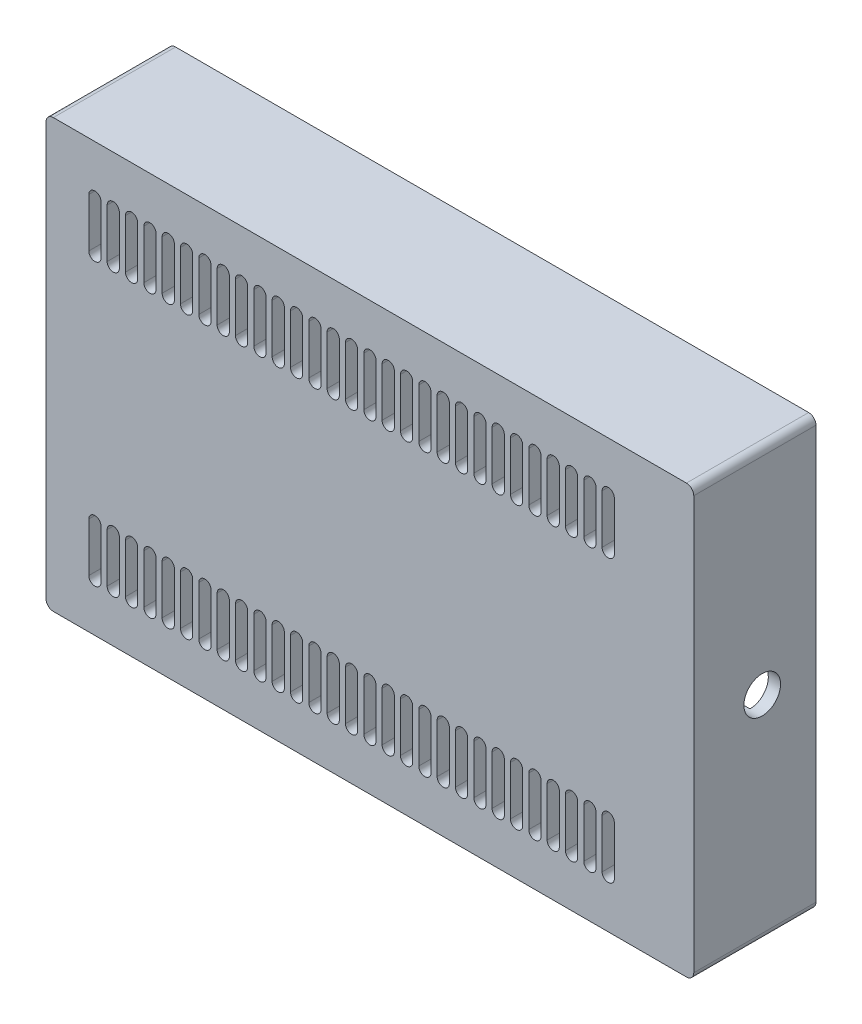
from build123d import *

# Parameters (mm, degrees)
SKETCH1_W             = 265
SKETCH1_H             = 175
BOSS_EXTRUDE1_DEPTH   = 50
SHELL1_T              = -5
FILLET1_R             = 3
SKETCH22_W            = 115
SKETCH22_H            = 70
CUT_EXTRUDE2_DEPTH    = 1.5
SKETCH15_R            = 4
BOSS_EXTRUDE5_DEPTH   = 13.95
FILLET3_R             = 5
SKETCH16_R            = 2.5
BOSS_EXTRUDE6_DEPTH   = 3
SKETCH23_W            = 15
SKETCH23_H            = 35
BOSS_EXTRUDE7_DEPTH   = 23
SKETCH27_R            = 1.65
CUT_EXTRUDE5_DEPTH    = 23
RIB1_REACH            = 174.187
SKETCH19_WALLS_W      = 2
SKETCH19_WALLS_H      = 353.383403917
RIB2_REACH            = 174.187
SKETCH20_WALLS_W      = 375.258359016
SKETCH20_WALLS_H      = 2
RIB12_REACH           = 174.187
SKETCH36_WALLS_W      = 360.258359016
SKETCH36_WALLS_H      = 2
SKETCH21_R            = 1.25
CUT_EXTRUDE1_DEPTH    = 13.95
SKETCH25_R            = 7.5
CUT_EXTRUDE3_DEPTH    = 21.1
FILLET4_R             = 3
CUT_EXTRUDE4_DEPTH    = 15
LPATTERN2_COUNT       = 29
LPATTERN2_PITCH       = 7.5
MIRROR3_COPY_1_DEPTH  = 15
MIRROR3_COPY_2_DEPTH  = 15
MIRROR3_COPY_3_DEPTH  = 15
MIRROR3_COPY_4_DEPTH  = 15
MIRROR3_COPY_5_DEPTH  = 15
MIRROR3_COPY_6_DEPTH  = 15
MIRROR3_COPY_7_DEPTH  = 15
MIRROR3_COPY_8_DEPTH  = 15
MIRROR3_COPY_9_DEPTH  = 15
MIRROR3_COPY_10_DEPTH = 15
MIRROR3_COPY_11_DEPTH = 15
MIRROR3_COPY_12_DEPTH = 15
MIRROR3_COPY_13_DEPTH = 15
MIRROR3_COPY_14_DEPTH = 15
MIRROR3_COPY_15_DEPTH = 15
MIRROR3_COPY_16_DEPTH = 15
MIRROR3_COPY_17_DEPTH = 15
MIRROR3_COPY_18_DEPTH = 15
MIRROR3_COPY_19_DEPTH = 15
MIRROR3_COPY_20_DEPTH = 15
MIRROR3_COPY_21_DEPTH = 15
MIRROR3_COPY_22_DEPTH = 15
MIRROR3_COPY_23_DEPTH = 15
MIRROR3_COPY_24_DEPTH = 15
MIRROR3_COPY_25_DEPTH = 15
MIRROR3_COPY_26_DEPTH = 15
MIRROR3_COPY_27_DEPTH = 15
MIRROR3_COPY_28_DEPTH = 15
SKETCH33_W            = 12
SKETCH33_H            = 13.5
CUT_EXTRUDE6_DEPTH    = 10.5


with BuildPart() as part:
    # Sketch1 → Boss-Extrude1 (new body)
    with BuildSketch(Plane.XY):
        with Locations((12.51, 0)):
            Rectangle(SKETCH1_W, SKETCH1_H)
    extrude(amount=BOSS_EXTRUDE1_DEPTH)

    # Shell1
    shell1_openings = [part.faces().sort_by_distance(p)[0] for p in [
        (12.51, 0, 0),
    ]]
    offset(amount=SHELL1_T, openings=shell1_openings, kind=Kind.INTERSECTION)

    # Fillet1
    fillet1_edges = [part.edges().sort_by_distance(p)[0] for p in [
        (-119.99, -87.5, 25),
        (145.01, -87.5, 25),
        (145.01, 87.5, 25),
        (-119.99, 87.5, 25),
    ]]
    fillet(fillet1_edges, radius=FILLET1_R)

    # Sketch22 → Cut-Extrude2 (cut)
    with BuildSketch(Plane(origin=(0, 0, 45), x_dir=(-1, 0, 0), z_dir=(0, 0, -1))):
        with Locations((47.5, 0)):
            Rectangle(SKETCH22_W, SKETCH22_H)
    extrude(amount=-CUT_EXTRUDE2_DEPTH, mode=Mode.SUBTRACT)

    # Sketch15 → Boss-Extrude5 (add)
    with BuildSketch(Plane(origin=(0, 0, 45), x_dir=(-1, 0, 0), z_dir=(0, 0, -1))):
        with Locations((-111.125, -3.89)):
            Circle(SKETCH15_R)
        with Locations((-111.125, 75.489955099)):
            Circle(SKETCH15_R)
        with Locations((111.125, -76.910044901)):
            Circle(SKETCH15_R)
        with Locations((-111.125, -76.910044901)):
            Circle(SKETCH15_R)
        with Locations((111.125, 75.489955099)):
            Circle(SKETCH15_R)
        with Locations((-57.15, 75.489955099)):
            Circle(SKETCH15_R)
        with Locations((0, 75.489955099)):
            Circle(SKETCH15_R)
        with Locations((57.145, 75.489955099)):
            Circle(SKETCH15_R)
        with Locations((-57.15, -76.910044901)):
            Circle(SKETCH15_R)
        with Locations((0, -76.910044901)):
            Circle(SKETCH15_R)
        with Locations((57.145, -76.910044901)):
            Circle(SKETCH15_R)
    extrude(amount=BOSS_EXTRUDE5_DEPTH)

    # Fillet3
    fillet3_edges = [part.edges().sort_by_distance(p)[0] for p in [
        (10, -35, 45.75),
        (10, 35, 45.75),
        (-105, 35, 45.75),
        (-105, -35, 45.75),
    ]]
    fillet(fillet3_edges, radius=FILLET3_R)

    # Sketch16 → Boss-Extrude6 (add)
    with BuildSketch(Plane(origin=(0, 0, 46.5), x_dir=(-1, 0, 0), z_dir=(0, 0, -1))):
        with Locations((85.245, -24.970044901)):
            Circle(SKETCH16_R)
        with Locations((10.115, -24.970042101)):
            Circle(SKETCH16_R)
        with Locations((34.445, -9.770044901)):
            Circle(SKETCH16_R)
        with Locations((3.035, 23.229955099)):
            Circle(SKETCH16_R)
        with Locations((34.445, 18.129955099)):
            Circle(SKETCH16_R)
        with Locations((85.665, 23.229955099)):
            Circle(SKETCH16_R)
    extrude(amount=BOSS_EXTRUDE6_DEPTH)

    # Sketch23 → Boss-Extrude7 (add)
    with BuildSketch(Plane(origin=(0, 0, 45), x_dir=(-1, 0, 0), z_dir=(0, 0, -1))):
        with Locations((-132.51, 0)):
            Rectangle(SKETCH23_W, SKETCH23_H)
    extrude(amount=BOSS_EXTRUDE7_DEPTH)

    # Sketch27 → Cut-Extrude5 (cut)
    with BuildSketch(Plane(origin=(0, 0, 22), x_dir=(-1, 0, 0), z_dir=(0, 0, -1))):
        with Locations((-132.51, -12)):
            Circle(SKETCH27_R)
        with Locations((-132.51, 12)):
            Circle(SKETCH27_R)
    extrude(amount=-CUT_EXTRUDE5_DEPTH, mode=Mode.SUBTRACT)

    # Sketch19 walls → Rib1 (add, up to next)
    with BuildSketch(Plane(origin=(0, 0, 31.05), x_dir=(-1, 0, 0), z_dir=(0, 0, -1)), mode=Mode.PRIVATE) as rib1_sk1:
        with Locations((-57.15, 78.99497755)):
            Rectangle(SKETCH19_WALLS_W, SKETCH19_WALLS_H)
    rib1_tool1 = extrude(rib1_sk1.sketch, amount=-RIB1_REACH, mode=Mode.PRIVATE) - part.part
    # Sketch19 walls → Rib1 (add, up to next)
    with BuildSketch(Plane(origin=(0, 0, 31.05), x_dir=(-1, 0, 0), z_dir=(0, 0, -1)), mode=Mode.PRIVATE) as rib1_sk2:
        with Locations((-111.125, 78.99497755)):
            Rectangle(SKETCH19_WALLS_W, SKETCH19_WALLS_H)
    rib1_tool2 = extrude(rib1_sk2.sketch, amount=-RIB1_REACH, mode=Mode.PRIVATE) - part.part
    # Sketch19 walls → Rib1 (add, up to next)
    with BuildSketch(Plane(origin=(0, 0, 31.05), x_dir=(-1, 0, 0), z_dir=(0, 0, -1)), mode=Mode.PRIVATE) as rib1_sk3:
        with Locations((0, 78.99497755)):
            Rectangle(SKETCH19_WALLS_W, SKETCH19_WALLS_H)
    rib1_tool3 = extrude(rib1_sk3.sketch, amount=-RIB1_REACH, mode=Mode.PRIVATE) - part.part
    # Sketch19 walls → Rib1 (add, up to next)
    with BuildSketch(Plane(origin=(0, 0, 31.05), x_dir=(-1, 0, 0), z_dir=(0, 0, -1)), mode=Mode.PRIVATE) as rib1_sk4:
        with Locations((57.145, 78.99497755)):
            Rectangle(SKETCH19_WALLS_W, SKETCH19_WALLS_H)
    rib1_tool4 = extrude(rib1_sk4.sketch, amount=-RIB1_REACH, mode=Mode.PRIVATE) - part.part
    # Sketch19 walls → Rib1 (add, up to next)
    with BuildSketch(Plane(origin=(0, 0, 31.05), x_dir=(-1, 0, 0), z_dir=(0, 0, -1)), mode=Mode.PRIVATE) as rib1_sk5:
        with Locations((111.125, 78.99497755)):
            Rectangle(SKETCH19_WALLS_W, SKETCH19_WALLS_H)
    rib1_tool5 = extrude(rib1_sk5.sketch, amount=-RIB1_REACH, mode=Mode.PRIVATE) - part.part
    rib1_1 = rib1_tool1.solids().sort_by_distance((57.15, 78.99497755, 31.05))[0]
    add(rib1_1)
    rib1_2 = rib1_tool2.solids().sort_by_distance((111.125, 78.99497755, 31.05))[0]
    add(rib1_2)
    rib1_3 = rib1_tool3.solids().sort_by_distance((0, 78.99497755, 31.05))[0]
    add(rib1_3)
    rib1_4 = rib1_tool4.solids().sort_by_distance((-57.145, 78.99497755, 31.05))[0]
    add(rib1_4)
    rib1_5 = rib1_tool5.solids().sort_by_distance((-111.125, 78.99497755, 31.05))[0]
    add(rib1_5)
    rib1 = rib1_1 + rib1_2 + rib1_3 + rib1_4 + rib1_5  # Rib1 as one shape, for the pattern or mirror that repeats it

    # Sketch20 walls → Rib2 (add, up to next)
    with BuildSketch(Plane(origin=(0, 0, 31.05), x_dir=(-1, 0, 0), z_dir=(0, 0, -1)), mode=Mode.PRIVATE) as rib2_sk1:
        with Locations((-125.5675, 75.489955099)):
            Rectangle(SKETCH20_WALLS_W, SKETCH20_WALLS_H)
    rib2_tool1 = extrude(rib2_sk1.sketch, amount=-RIB2_REACH, mode=Mode.PRIVATE) - part.part
    # Sketch20 walls → Rib2 (add, up to next)
    with BuildSketch(Plane(origin=(0, 0, 31.05), x_dir=(-1, 0, 0), z_dir=(0, 0, -1)), mode=Mode.PRIVATE) as rib2_sk2:
        with Locations((-125.5675, -76.910044901)):
            Rectangle(SKETCH20_WALLS_W, SKETCH20_WALLS_H)
    rib2_tool2 = extrude(rib2_sk2.sketch, amount=-RIB2_REACH, mode=Mode.PRIVATE) - part.part
    add(rib2_tool1.solids().sort_by_distance((125.5675, 75.489955099, 31.05))[0])
    add(rib2_tool2.solids().sort_by_distance((125.5675, -76.910044901, 31.05))[0])

    # Sketch36 walls → Rib12 (add, up to next)
    with BuildSketch(Plane(origin=(0, 0, 31.05), x_dir=(-1, 0, 0), z_dir=(0, 0, -1)), mode=Mode.PRIVATE) as rib12_sk1:
        with Locations((-118.0675, -3.89)):
            Rectangle(SKETCH36_WALLS_W, SKETCH36_WALLS_H)
    rib12_tool1 = extrude(rib12_sk1.sketch, amount=-RIB12_REACH, mode=Mode.PRIVATE) - part.part
    add(rib12_tool1.solids().sort_by_distance((118.0675, -3.89, 31.05))[0])

    # Mirror2: Rib1 across plane
    add(rib1.mirror(Plane.ZX))

    # Sketch21 → Cut-Extrude1 (cut)
    with BuildSketch(Plane(origin=(0, 0, 31.05), x_dir=(-1, 0, 0), z_dir=(0, 0, -1))):
        with Locations((-111.125, 75.489955099)):
            Circle(SKETCH21_R)
        with Locations((-57.15, 75.489955099)):
            Circle(SKETCH21_R)
        with Locations((0, 75.489955099)):
            Circle(SKETCH21_R)
        with Locations((57.145, 75.489955099)):
            Circle(SKETCH21_R)
        with Locations((111.125, 75.489955099)):
            Circle(SKETCH21_R)
        with Locations((111.125, -76.910044901)):
            Circle(SKETCH21_R)
        with Locations((57.145, -76.910044901)):
            Circle(SKETCH21_R)
        with Locations((0, -76.910044901)):
            Circle(SKETCH21_R)
        with Locations((-57.15, -76.910044901)):
            Circle(SKETCH21_R)
        with Locations((-111.125, -76.910044901)):
            Circle(SKETCH21_R)
        with Locations((-111.125, -3.89)):
            Circle(SKETCH21_R)
    extrude(amount=-CUT_EXTRUDE1_DEPTH, mode=Mode.SUBTRACT)

    # Sketch25 → Cut-Extrude3 (cut)
    with BuildSketch(Plane.ZY.offset(-125.01)):
        with Locations((22, 0)):
            Circle(SKETCH25_R)
    extrude(amount=-CUT_EXTRUDE3_DEPTH, mode=Mode.SUBTRACT)

    # Fillet4
    fillet4_edges = [part.edges().sort_by_distance(p)[0] for p in [
        (125.01, -17.5, 33.5),
        (125.01, 17.5, 33.5),
    ]]
    fillet(fillet4_edges, radius=FILLET4_R)

    # Sketch28 → Cut-Extrude4 (cut)
    with BuildSketch(Plane.XY.offset(50)):
        with BuildLine():
            Line((-102.49, 47.5), (-102.49, 67.5))
            ThreePointArc((-102.49, 67.5), (-99.99, 70), (-97.49, 67.5))
            Line((-97.49, 67.5), (-97.49, 47.5))
            ThreePointArc((-97.49, 47.5), (-99.99, 45), (-102.49, 47.5))
        make_face()
    cut_extrude4 = extrude(amount=-CUT_EXTRUDE4_DEPTH, mode=Mode.SUBTRACT)

    # LPattern2: Cut-Extrude4 ×29
    with Locations(*[(i * LPATTERN2_PITCH, 0, 0) for i in range(1, LPATTERN2_COUNT)]):
        add(cut_extrude4, mode=Mode.SUBTRACT)

    # Mirror3: Cut-Extrude4 across plane
    add(cut_extrude4.mirror(Plane.ZX), mode=Mode.SUBTRACT)

    # Mirror3 copy 1 sketch → Mirror3 copy 1 (cut)
    with BuildSketch(Plane(origin=(7.5, 0, 50), x_dir=(1, 0, 0), z_dir=(0, 0, 1))):
        with BuildLine():
            Line((-102.49, -47.5), (-102.49, -67.5))
            ThreePointArc((-102.49, -67.5), (-99.99, -70), (-97.49, -67.5))
            Line((-97.49, -67.5), (-97.49, -47.5))
            ThreePointArc((-97.49, -47.5), (-99.99, -45), (-102.49, -47.5))
        make_face()
    extrude(amount=-MIRROR3_COPY_1_DEPTH, mode=Mode.SUBTRACT)

    # Mirror3 copy 2 sketch → Mirror3 copy 2 (cut)
    with BuildSketch(Plane(origin=(15, 0, 50), x_dir=(1, 0, 0), z_dir=(0, 0, 1))):
        with BuildLine():
            Line((-102.49, -47.5), (-102.49, -67.5))
            ThreePointArc((-102.49, -67.5), (-99.99, -70), (-97.49, -67.5))
            Line((-97.49, -67.5), (-97.49, -47.5))
            ThreePointArc((-97.49, -47.5), (-99.99, -45), (-102.49, -47.5))
        make_face()
    extrude(amount=-MIRROR3_COPY_2_DEPTH, mode=Mode.SUBTRACT)

    # Mirror3 copy 3 sketch → Mirror3 copy 3 (cut)
    with BuildSketch(Plane(origin=(22.5, 0, 50), x_dir=(1, 0, 0), z_dir=(0, 0, 1))):
        with BuildLine():
            Line((-102.49, -47.5), (-102.49, -67.5))
            ThreePointArc((-102.49, -67.5), (-99.99, -70), (-97.49, -67.5))
            Line((-97.49, -67.5), (-97.49, -47.5))
            ThreePointArc((-97.49, -47.5), (-99.99, -45), (-102.49, -47.5))
        make_face()
    extrude(amount=-MIRROR3_COPY_3_DEPTH, mode=Mode.SUBTRACT)

    # Mirror3 copy 4 sketch → Mirror3 copy 4 (cut)
    with BuildSketch(Plane(origin=(30, 0, 50), x_dir=(1, 0, 0), z_dir=(0, 0, 1))):
        with BuildLine():
            Line((-102.49, -47.5), (-102.49, -67.5))
            ThreePointArc((-102.49, -67.5), (-99.99, -70), (-97.49, -67.5))
            Line((-97.49, -67.5), (-97.49, -47.5))
            ThreePointArc((-97.49, -47.5), (-99.99, -45), (-102.49, -47.5))
        make_face()
    extrude(amount=-MIRROR3_COPY_4_DEPTH, mode=Mode.SUBTRACT)

    # Mirror3 copy 5 sketch → Mirror3 copy 5 (cut)
    with BuildSketch(Plane(origin=(37.5, 0, 50), x_dir=(1, 0, 0), z_dir=(0, 0, 1))):
        with BuildLine():
            Line((-102.49, -47.5), (-102.49, -67.5))
            ThreePointArc((-102.49, -67.5), (-99.99, -70), (-97.49, -67.5))
            Line((-97.49, -67.5), (-97.49, -47.5))
            ThreePointArc((-97.49, -47.5), (-99.99, -45), (-102.49, -47.5))
        make_face()
    extrude(amount=-MIRROR3_COPY_5_DEPTH, mode=Mode.SUBTRACT)

    # Mirror3 copy 6 sketch → Mirror3 copy 6 (cut)
    with BuildSketch(Plane(origin=(45, 0, 50), x_dir=(1, 0, 0), z_dir=(0, 0, 1))):
        with BuildLine():
            Line((-102.49, -47.5), (-102.49, -67.5))
            ThreePointArc((-102.49, -67.5), (-99.99, -70), (-97.49, -67.5))
            Line((-97.49, -67.5), (-97.49, -47.5))
            ThreePointArc((-97.49, -47.5), (-99.99, -45), (-102.49, -47.5))
        make_face()
    extrude(amount=-MIRROR3_COPY_6_DEPTH, mode=Mode.SUBTRACT)

    # Mirror3 copy 7 sketch → Mirror3 copy 7 (cut)
    with BuildSketch(Plane(origin=(52.5, 0, 50), x_dir=(1, 0, 0), z_dir=(0, 0, 1))):
        with BuildLine():
            Line((-102.49, -47.5), (-102.49, -67.5))
            ThreePointArc((-102.49, -67.5), (-99.99, -70), (-97.49, -67.5))
            Line((-97.49, -67.5), (-97.49, -47.5))
            ThreePointArc((-97.49, -47.5), (-99.99, -45), (-102.49, -47.5))
        make_face()
    extrude(amount=-MIRROR3_COPY_7_DEPTH, mode=Mode.SUBTRACT)

    # Mirror3 copy 8 sketch → Mirror3 copy 8 (cut)
    with BuildSketch(Plane(origin=(60, 0, 50), x_dir=(1, 0, 0), z_dir=(0, 0, 1))):
        with BuildLine():
            Line((-102.49, -47.5), (-102.49, -67.5))
            ThreePointArc((-102.49, -67.5), (-99.99, -70), (-97.49, -67.5))
            Line((-97.49, -67.5), (-97.49, -47.5))
            ThreePointArc((-97.49, -47.5), (-99.99, -45), (-102.49, -47.5))
        make_face()
    extrude(amount=-MIRROR3_COPY_8_DEPTH, mode=Mode.SUBTRACT)

    # Mirror3 copy 9 sketch → Mirror3 copy 9 (cut)
    with BuildSketch(Plane(origin=(67.5, 0, 50), x_dir=(1, 0, 0), z_dir=(0, 0, 1))):
        with BuildLine():
            Line((-102.49, -47.5), (-102.49, -67.5))
            ThreePointArc((-102.49, -67.5), (-99.99, -70), (-97.49, -67.5))
            Line((-97.49, -67.5), (-97.49, -47.5))
            ThreePointArc((-97.49, -47.5), (-99.99, -45), (-102.49, -47.5))
        make_face()
    extrude(amount=-MIRROR3_COPY_9_DEPTH, mode=Mode.SUBTRACT)

    # Mirror3 copy 10 sketch → Mirror3 copy 10 (cut)
    with BuildSketch(Plane(origin=(75, 0, 50), x_dir=(1, 0, 0), z_dir=(0, 0, 1))):
        with BuildLine():
            Line((-102.49, -47.5), (-102.49, -67.5))
            ThreePointArc((-102.49, -67.5), (-99.99, -70), (-97.49, -67.5))
            Line((-97.49, -67.5), (-97.49, -47.5))
            ThreePointArc((-97.49, -47.5), (-99.99, -45), (-102.49, -47.5))
        make_face()
    extrude(amount=-MIRROR3_COPY_10_DEPTH, mode=Mode.SUBTRACT)

    # Mirror3 copy 11 sketch → Mirror3 copy 11 (cut)
    with BuildSketch(Plane(origin=(82.5, 0, 50), x_dir=(1, 0, 0), z_dir=(0, 0, 1))):
        with BuildLine():
            Line((-102.49, -47.5), (-102.49, -67.5))
            ThreePointArc((-102.49, -67.5), (-99.99, -70), (-97.49, -67.5))
            Line((-97.49, -67.5), (-97.49, -47.5))
            ThreePointArc((-97.49, -47.5), (-99.99, -45), (-102.49, -47.5))
        make_face()
    extrude(amount=-MIRROR3_COPY_11_DEPTH, mode=Mode.SUBTRACT)

    # Mirror3 copy 12 sketch → Mirror3 copy 12 (cut)
    with BuildSketch(Plane(origin=(90, 0, 50), x_dir=(1, 0, 0), z_dir=(0, 0, 1))):
        with BuildLine():
            Line((-102.49, -47.5), (-102.49, -67.5))
            ThreePointArc((-102.49, -67.5), (-99.99, -70), (-97.49, -67.5))
            Line((-97.49, -67.5), (-97.49, -47.5))
            ThreePointArc((-97.49, -47.5), (-99.99, -45), (-102.49, -47.5))
        make_face()
    extrude(amount=-MIRROR3_COPY_12_DEPTH, mode=Mode.SUBTRACT)

    # Mirror3 copy 13 sketch → Mirror3 copy 13 (cut)
    with BuildSketch(Plane(origin=(97.5, 0, 50), x_dir=(1, 0, 0), z_dir=(0, 0, 1))):
        with BuildLine():
            Line((-102.49, -47.5), (-102.49, -67.5))
            ThreePointArc((-102.49, -67.5), (-99.99, -70), (-97.49, -67.5))
            Line((-97.49, -67.5), (-97.49, -47.5))
            ThreePointArc((-97.49, -47.5), (-99.99, -45), (-102.49, -47.5))
        make_face()
    extrude(amount=-MIRROR3_COPY_13_DEPTH, mode=Mode.SUBTRACT)

    # Mirror3 copy 14 sketch → Mirror3 copy 14 (cut)
    with BuildSketch(Plane(origin=(105, 0, 50), x_dir=(1, 0, 0), z_dir=(0, 0, 1))):
        with BuildLine():
            Line((-102.49, -47.5), (-102.49, -67.5))
            ThreePointArc((-102.49, -67.5), (-99.99, -70), (-97.49, -67.5))
            Line((-97.49, -67.5), (-97.49, -47.5))
            ThreePointArc((-97.49, -47.5), (-99.99, -45), (-102.49, -47.5))
        make_face()
    extrude(amount=-MIRROR3_COPY_14_DEPTH, mode=Mode.SUBTRACT)

    # Mirror3 copy 15 sketch → Mirror3 copy 15 (cut)
    with BuildSketch(Plane(origin=(112.5, 0, 50), x_dir=(1, 0, 0), z_dir=(0, 0, 1))):
        with BuildLine():
            Line((-102.49, -47.5), (-102.49, -67.5))
            ThreePointArc((-102.49, -67.5), (-99.99, -70), (-97.49, -67.5))
            Line((-97.49, -67.5), (-97.49, -47.5))
            ThreePointArc((-97.49, -47.5), (-99.99, -45), (-102.49, -47.5))
        make_face()
    extrude(amount=-MIRROR3_COPY_15_DEPTH, mode=Mode.SUBTRACT)

    # Mirror3 copy 16 sketch → Mirror3 copy 16 (cut)
    with BuildSketch(Plane(origin=(120, 0, 50), x_dir=(1, 0, 0), z_dir=(0, 0, 1))):
        with BuildLine():
            Line((-102.49, -47.5), (-102.49, -67.5))
            ThreePointArc((-102.49, -67.5), (-99.99, -70), (-97.49, -67.5))
            Line((-97.49, -67.5), (-97.49, -47.5))
            ThreePointArc((-97.49, -47.5), (-99.99, -45), (-102.49, -47.5))
        make_face()
    extrude(amount=-MIRROR3_COPY_16_DEPTH, mode=Mode.SUBTRACT)

    # Mirror3 copy 17 sketch → Mirror3 copy 17 (cut)
    with BuildSketch(Plane(origin=(127.5, 0, 50), x_dir=(1, 0, 0), z_dir=(0, 0, 1))):
        with BuildLine():
            Line((-102.49, -47.5), (-102.49, -67.5))
            ThreePointArc((-102.49, -67.5), (-99.99, -70), (-97.49, -67.5))
            Line((-97.49, -67.5), (-97.49, -47.5))
            ThreePointArc((-97.49, -47.5), (-99.99, -45), (-102.49, -47.5))
        make_face()
    extrude(amount=-MIRROR3_COPY_17_DEPTH, mode=Mode.SUBTRACT)

    # Mirror3 copy 18 sketch → Mirror3 copy 18 (cut)
    with BuildSketch(Plane(origin=(135, 0, 50), x_dir=(1, 0, 0), z_dir=(0, 0, 1))):
        with BuildLine():
            Line((-102.49, -47.5), (-102.49, -67.5))
            ThreePointArc((-102.49, -67.5), (-99.99, -70), (-97.49, -67.5))
            Line((-97.49, -67.5), (-97.49, -47.5))
            ThreePointArc((-97.49, -47.5), (-99.99, -45), (-102.49, -47.5))
        make_face()
    extrude(amount=-MIRROR3_COPY_18_DEPTH, mode=Mode.SUBTRACT)

    # Mirror3 copy 19 sketch → Mirror3 copy 19 (cut)
    with BuildSketch(Plane(origin=(142.5, 0, 50), x_dir=(1, 0, 0), z_dir=(0, 0, 1))):
        with BuildLine():
            Line((-102.49, -47.5), (-102.49, -67.5))
            ThreePointArc((-102.49, -67.5), (-99.99, -70), (-97.49, -67.5))
            Line((-97.49, -67.5), (-97.49, -47.5))
            ThreePointArc((-97.49, -47.5), (-99.99, -45), (-102.49, -47.5))
        make_face()
    extrude(amount=-MIRROR3_COPY_19_DEPTH, mode=Mode.SUBTRACT)

    # Mirror3 copy 20 sketch → Mirror3 copy 20 (cut)
    with BuildSketch(Plane(origin=(150, 0, 50), x_dir=(1, 0, 0), z_dir=(0, 0, 1))):
        with BuildLine():
            Line((-102.49, -47.5), (-102.49, -67.5))
            ThreePointArc((-102.49, -67.5), (-99.99, -70), (-97.49, -67.5))
            Line((-97.49, -67.5), (-97.49, -47.5))
            ThreePointArc((-97.49, -47.5), (-99.99, -45), (-102.49, -47.5))
        make_face()
    extrude(amount=-MIRROR3_COPY_20_DEPTH, mode=Mode.SUBTRACT)

    # Mirror3 copy 21 sketch → Mirror3 copy 21 (cut)
    with BuildSketch(Plane(origin=(157.5, 0, 50), x_dir=(1, 0, 0), z_dir=(0, 0, 1))):
        with BuildLine():
            Line((-102.49, -47.5), (-102.49, -67.5))
            ThreePointArc((-102.49, -67.5), (-99.99, -70), (-97.49, -67.5))
            Line((-97.49, -67.5), (-97.49, -47.5))
            ThreePointArc((-97.49, -47.5), (-99.99, -45), (-102.49, -47.5))
        make_face()
    extrude(amount=-MIRROR3_COPY_21_DEPTH, mode=Mode.SUBTRACT)

    # Mirror3 copy 22 sketch → Mirror3 copy 22 (cut)
    with BuildSketch(Plane(origin=(165, 0, 50), x_dir=(1, 0, 0), z_dir=(0, 0, 1))):
        with BuildLine():
            Line((-102.49, -47.5), (-102.49, -67.5))
            ThreePointArc((-102.49, -67.5), (-99.99, -70), (-97.49, -67.5))
            Line((-97.49, -67.5), (-97.49, -47.5))
            ThreePointArc((-97.49, -47.5), (-99.99, -45), (-102.49, -47.5))
        make_face()
    extrude(amount=-MIRROR3_COPY_22_DEPTH, mode=Mode.SUBTRACT)

    # Mirror3 copy 23 sketch → Mirror3 copy 23 (cut)
    with BuildSketch(Plane(origin=(172.5, 0, 50), x_dir=(1, 0, 0), z_dir=(0, 0, 1))):
        with BuildLine():
            Line((-102.49, -47.5), (-102.49, -67.5))
            ThreePointArc((-102.49, -67.5), (-99.99, -70), (-97.49, -67.5))
            Line((-97.49, -67.5), (-97.49, -47.5))
            ThreePointArc((-97.49, -47.5), (-99.99, -45), (-102.49, -47.5))
        make_face()
    extrude(amount=-MIRROR3_COPY_23_DEPTH, mode=Mode.SUBTRACT)

    # Mirror3 copy 24 sketch → Mirror3 copy 24 (cut)
    with BuildSketch(Plane(origin=(180, 0, 50), x_dir=(1, 0, 0), z_dir=(0, 0, 1))):
        with BuildLine():
            Line((-102.49, -47.5), (-102.49, -67.5))
            ThreePointArc((-102.49, -67.5), (-99.99, -70), (-97.49, -67.5))
            Line((-97.49, -67.5), (-97.49, -47.5))
            ThreePointArc((-97.49, -47.5), (-99.99, -45), (-102.49, -47.5))
        make_face()
    extrude(amount=-MIRROR3_COPY_24_DEPTH, mode=Mode.SUBTRACT)

    # Mirror3 copy 25 sketch → Mirror3 copy 25 (cut)
    with BuildSketch(Plane(origin=(187.5, 0, 50), x_dir=(1, 0, 0), z_dir=(0, 0, 1))):
        with BuildLine():
            Line((-102.49, -47.5), (-102.49, -67.5))
            ThreePointArc((-102.49, -67.5), (-99.99, -70), (-97.49, -67.5))
            Line((-97.49, -67.5), (-97.49, -47.5))
            ThreePointArc((-97.49, -47.5), (-99.99, -45), (-102.49, -47.5))
        make_face()
    extrude(amount=-MIRROR3_COPY_25_DEPTH, mode=Mode.SUBTRACT)

    # Mirror3 copy 26 sketch → Mirror3 copy 26 (cut)
    with BuildSketch(Plane(origin=(195, 0, 50), x_dir=(1, 0, 0), z_dir=(0, 0, 1))):
        with BuildLine():
            Line((-102.49, -47.5), (-102.49, -67.5))
            ThreePointArc((-102.49, -67.5), (-99.99, -70), (-97.49, -67.5))
            Line((-97.49, -67.5), (-97.49, -47.5))
            ThreePointArc((-97.49, -47.5), (-99.99, -45), (-102.49, -47.5))
        make_face()
    extrude(amount=-MIRROR3_COPY_26_DEPTH, mode=Mode.SUBTRACT)

    # Mirror3 copy 27 sketch → Mirror3 copy 27 (cut)
    with BuildSketch(Plane(origin=(202.5, 0, 50), x_dir=(1, 0, 0), z_dir=(0, 0, 1))):
        with BuildLine():
            Line((-102.49, -47.5), (-102.49, -67.5))
            ThreePointArc((-102.49, -67.5), (-99.99, -70), (-97.49, -67.5))
            Line((-97.49, -67.5), (-97.49, -47.5))
            ThreePointArc((-97.49, -47.5), (-99.99, -45), (-102.49, -47.5))
        make_face()
    extrude(amount=-MIRROR3_COPY_27_DEPTH, mode=Mode.SUBTRACT)

    # Mirror3 copy 28 sketch → Mirror3 copy 28 (cut)
    with BuildSketch(Plane(origin=(210, 0, 50), x_dir=(1, 0, 0), z_dir=(0, 0, 1))):
        with BuildLine():
            Line((-102.49, -47.5), (-102.49, -67.5))
            ThreePointArc((-102.49, -67.5), (-99.99, -70), (-97.49, -67.5))
            Line((-97.49, -67.5), (-97.49, -47.5))
            ThreePointArc((-97.49, -47.5), (-99.99, -45), (-102.49, -47.5))
        make_face()
    extrude(amount=-MIRROR3_COPY_28_DEPTH, mode=Mode.SUBTRACT)

    # Sketch33 → Cut-Extrude6 (cut)
    with BuildSketch(Plane.ZY.offset(119.99)):
        with Locations((38.95, -12.05)):
            Rectangle(SKETCH33_W, SKETCH33_H)
    extrude(amount=-CUT_EXTRUDE6_DEPTH, mode=Mode.SUBTRACT)


solid = part.part
